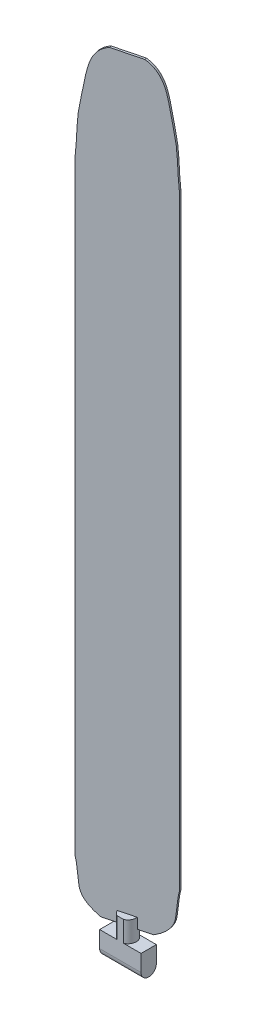
from build123d import *

# Parameters (mm, degrees)
EXTRUDE_1_DEPTH          = 10
EXTRUDE_2_DEPTH          = 10
EXTRUDE_3_DEPTH          = 360
EXTRUDE_3_DEPTH_BACK     = 5
CUT_EXTRUDE_1_DEPTH      = 10.938825861
CUT_EXTRUDE_1_DEPTH_BACK = 11.938825861


with BuildPart() as part:
    # 草图2 → 凸台-拉伸1 (new body, symmetric)
    with BuildSketch(Plane(origin=(-29.352134755, 0, 0), x_dir=(0, 0, -1), z_dir=(1, 0, 0))):
        with BuildLine():
            Line((-34.584801913, 63.517502407), (-34.584801913, 71.517502407))
            Line((-34.584801913, 71.517502407), (-27.184801913, 71.517502407))
            Line((-27.184801913, 71.517502407), (-27.184801913, 63.517502407))
            ThreePointArc((-27.184801913, 63.517502407), (-30.884801913, 59.817502407), (-34.584801913, 63.517502407))
        make_face()
    extrude(amount=EXTRUDE_1_DEPTH, both=True)

    # 草图4 → 凸台-拉伸2 (add)
    with BuildSketch(Plane(origin=(0, 71.517502407, 0), x_dir=(1, 0, 0), z_dir=(0, 1, 0))):
        with BuildLine():
            ThreePointArc((-30.872003171, -27.184801913), (-33.352134755, -30.884801913), (-30.872003171, -34.584801913))
            Line((-30.872003171, -34.584801913), (-27.83226634, -34.584801913))
            ThreePointArc((-27.83226634, -34.584801913), (-25.352134755, -30.884801913), (-27.83226634, -27.184801913))
            Line((-27.83226634, -27.184801913), (-30.872003171, -27.184801913))
        make_face()
    extrude(amount=EXTRUDE_2_DEPTH)

    # 草图7 → 凸台-拉伸3 (add, two sides)
    with BuildSketch(Plane(origin=(0, 81.517502407, 0), x_dir=(1, 0, 0), z_dir=(0, 1, 0))) as extrude_3_sk:
        Polygon((-49.227899432, -36.499423776), (-49.476370079, -35.53078435), (-9.476370079, -25.27018005), (-9.227899432, -26.238819476), align=None)
    extrude(amount=EXTRUDE_3_DEPTH)
    extrude(extrude_3_sk.sketch, amount=-EXTRUDE_3_DEPTH_BACK)

    # 草图8 → 切除-拉伸1 (cut, two sides)
    with BuildSketch(Plane(origin=(5.745409843, 0, 22.397939438), x_dir=(0.968639426, 0, -0.248470647), z_dir=(0.248470647, 0, 0.968639426))) as cut_extrude_1_sk:
        with BuildLine():
            Line((-56.753119678, 441.517502407), (-56.753119678, 391.692905165))
            add(Edge.make_bspline(
                [(-43.078776353, 441.517502407), (-51.216796387, 438.23058361), (-52.576278999, 425.112937891), (-56.382375341, 407.988441194), (-56.082947511, 397.823049203), (-56.753119678, 391.692905165)],
                knots=[0, 0, 0, 0, 0.351967416, 0.523137111, 0.799664718, 0.799664718, 0.799664718, 0.799664718], degree=3))
            Line((-43.078776353, 441.517502407), (-56.753119678, 441.517502407))
        make_face()
        with BuildLine():
            Line((-15.458083649, 441.517502407), (-29.132426973, 441.517502407))
            add(Edge.make_bspline(
                [(-29.132426973, 441.517502407), (-20.994406939, 438.23058361), (-19.634924328, 425.112937891), (-15.828827986, 407.988441194), (-16.128255816, 397.823049203), (-15.458083649, 391.692905165)],
                knots=[0, 0, 0, 0, 0.351967416, 0.523137111, 0.799664718, 0.799664718, 0.799664718, 0.799664718], degree=3))
            Line((-15.458083649, 391.692905165), (-15.458083649, 441.517502407))
        make_face()
        with BuildLine():
            Line((-15.458083649, 76.517502407), (-15.458083649, 98.17969781))
            add(Edge.make_bspline(
                [(-25.600815541, 76.517502407), (-22.657286276, 78.055965616), (-17.607813954, 81.639827622), (-16.337691235, 90.138636186), (-16.166046553, 95.417815279), (-15.458083649, 98.17969781)],
                knots=[0, 0, 0, 0, 0.237372494, 0.354242691, 0.564314689, 0.564314689, 0.564314689, 0.564314689], degree=3))
            Line((-25.600815541, 76.517502407), (-15.458083649, 76.517502407))
        make_face()
        with BuildLine():
            Line((-56.753119678, 76.517502407), (-46.610387786, 76.517502407))
            add(Edge.make_bspline(
                [(-46.610387786, 76.517502407), (-49.55391705, 78.055965616), (-54.603389372, 81.639827622), (-55.873512091, 90.138636186), (-56.045156774, 95.417815279), (-56.753119678, 98.17969781)],
                knots=[0, 0, 0, 0, 0.237372494, 0.354242691, 0.564314689, 0.564314689, 0.564314689, 0.564314689], degree=3))
            Line((-56.753119678, 98.17969781), (-56.753119678, 76.517502407))
        make_face()
    extrude(amount=CUT_EXTRUDE_1_DEPTH, mode=Mode.SUBTRACT)
    extrude(cut_extrude_1_sk.sketch, amount=-CUT_EXTRUDE_1_DEPTH_BACK, mode=Mode.SUBTRACT)


solid = part.part
